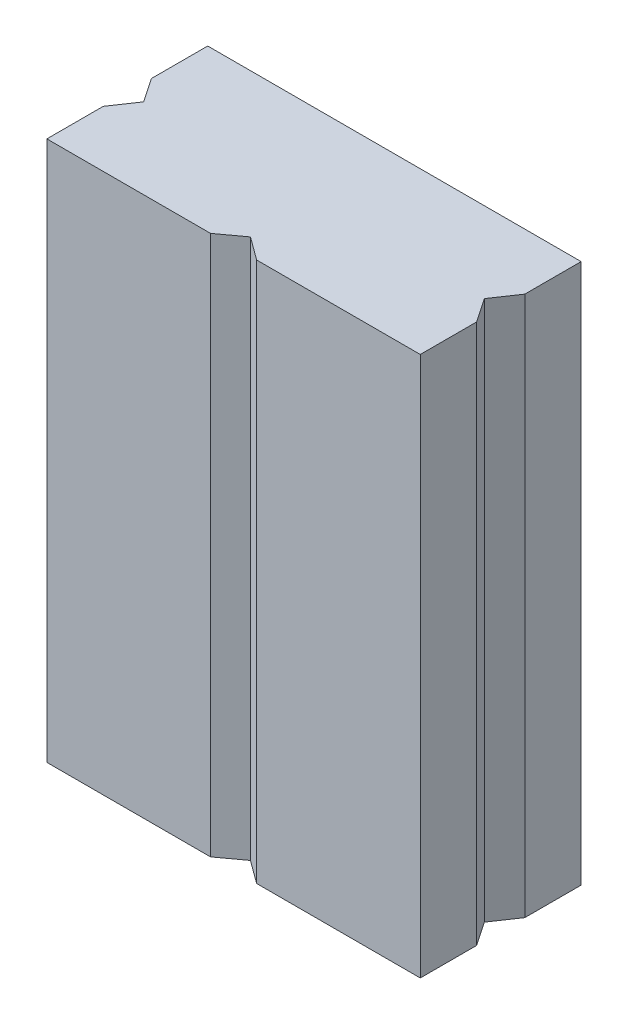
from build123d import *

# Parameters (mm, degrees)
BOSS_EXTRUDE1_DEPTH = 94
SKETCH1_3_R         = 2.40784246
CUT_EXTRUDE1_DEPTH  = 5


with BuildPart() as part:
    # Sketch1 → Boss-Extrude1 (new body)
    with BuildSketch(Plane(origin=(0, 0, 0), x_dir=(1, 0, 0), z_dir=(0, 1, 0))):
        Polygon((0, 9.805763686), (0, 0), (28.48646363, 0), (32.5, 2.93900405), (36.51353637, 0), (65, 0), (65, 9.805763686), (62.163382508, 14), (65, 18.194236314), (65, 28), (0, 28), (0, 18.194236314), (2.836617492, 14), align=None)
    extrude(amount=BOSS_EXTRUDE1_DEPTH)

    # Sketch1_3 → Cut-Extrude1 (cut)
    with BuildSketch(Plane(origin=(0, 0, 0), x_dir=(1, 0, 0), z_dir=(0, 1, 0))):
        with Locations((12.697649227, 14)):
            Circle(SKETCH1_3_R)
    extrude(amount=CUT_EXTRUDE1_DEPTH, mode=Mode.SUBTRACT)


solid = part.part
